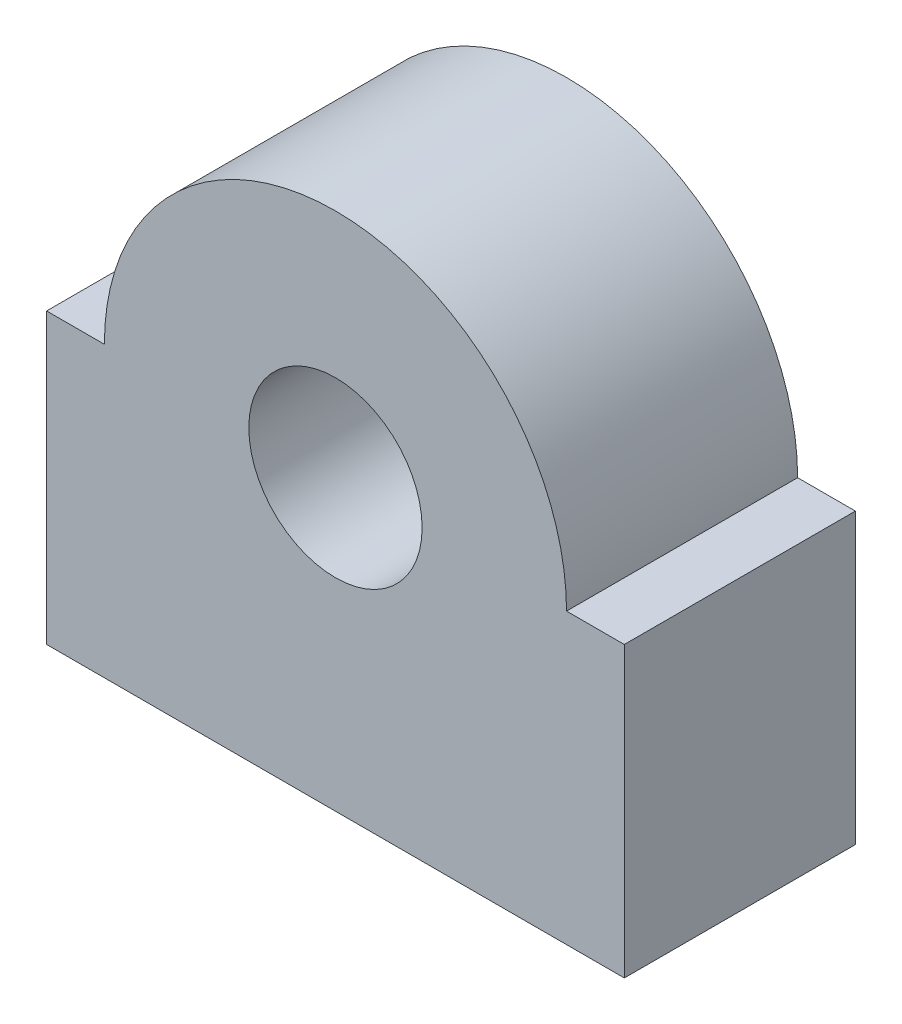
from build123d import *

# Parameters (mm, degrees)
SKETCH1_R           = 19.05
BOSS_EXTRUDE1_DEPTH = 50.8


with BuildPart() as part:
    # Sketch1 → Boss-Extrude1 (new body)
    with BuildSketch(Plane.XY):
        with BuildLine():
            Line((-63.5, 0), (63.5, 0))
            Line((63.5, 0), (63.5, 63.5))
            Line((63.5, 63.5), (50.8, 63.5))
            ThreePointArc((50.8, 63.5), (0, 114.3), (-50.8, 63.5))
            Line((-50.8, 63.5), (-63.5, 63.5))
            Line((-63.5, 63.5), (-63.5, 0))
        make_face()
        with Locations((0, 63.5)):
            Circle(SKETCH1_R, mode=Mode.SUBTRACT)
    extrude(amount=BOSS_EXTRUDE1_DEPTH)


solid = part.part
